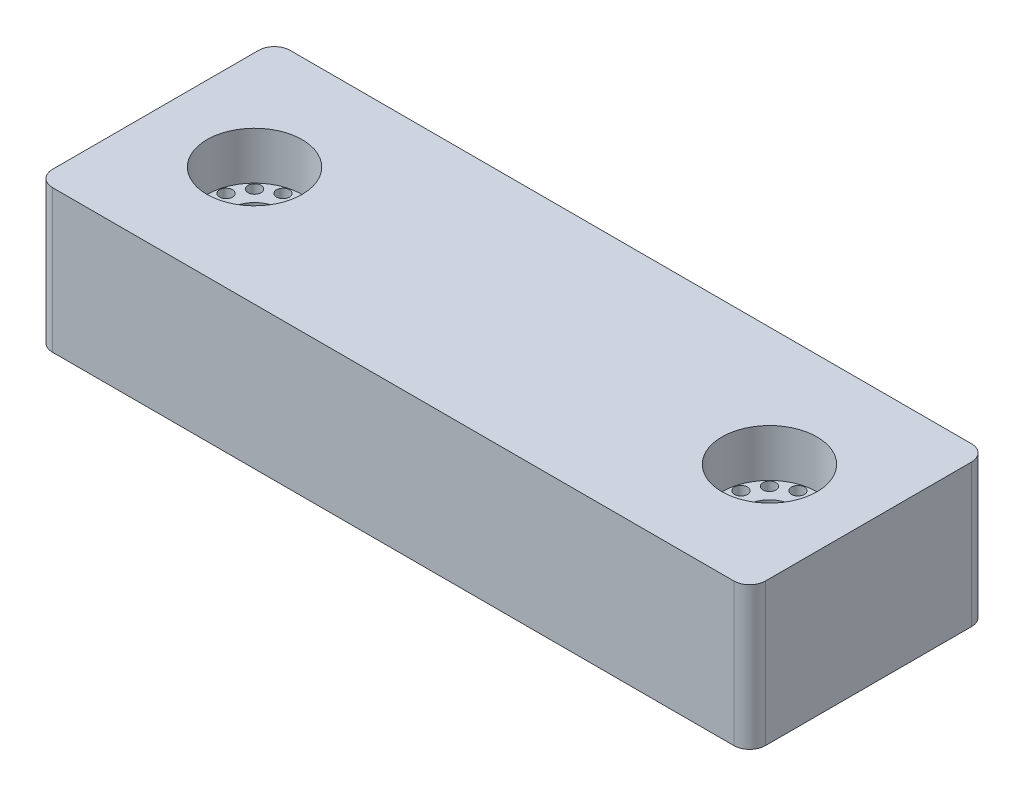
from build123d import *

# Parameters (mm, degrees)
SKETCH1_R           = 3
SKETCH1_R_2         = 0.815869739
BOSS_EXTRUDE1_DEPTH = 18
SKETCH2_R           = 6
CUT_EXTRUDE1_DEPTH  = 6


with BuildPart() as part:
    # Sketch1 → Boss-Extrude1 (new body)
    with BuildSketch(Plane(origin=(0, 0, 0), x_dir=(1, 0, 0), z_dir=(0, 1, 0))):
        with BuildLine():
            Line((-45, 13), (-45, -13))
            ThreePointArc((-45, -13), (-44.414213562, -14.414213562), (-43, -15))
            Line((-43, -15), (43, -15))
            ThreePointArc((43, -15), (44.414213562, -14.414213562), (45, -13))
            Line((45, -13), (45, 13))
            ThreePointArc((45, 13), (44.414213562, 14.414213562), (43, 15))
            Line((43, 15), (-43, 15))
            ThreePointArc((-43, 15), (-44.414213562, 14.414213562), (-45, 13))
        make_face()
        with Locations((-32.5, 0)):
            Circle(SKETCH1_R, mode=Mode.SUBTRACT)
        with Locations((32.5, 0)):
            Circle(SKETCH1_R, mode=Mode.SUBTRACT)
        with Locations((-31.184130261, 4.910892723)):
            Circle(SKETCH1_R_2, mode=Mode.SUBTRACT)
        with Locations((-33.815869739, 4.910892723)):
            Circle(SKETCH1_R_2, mode=Mode.SUBTRACT)
        with Locations((-36.095022984, 3.595022984)):
            Circle(SKETCH1_R_2, mode=Mode.SUBTRACT)
        with Locations((-37.410892723, 1.315869739)):
            Circle(SKETCH1_R_2, mode=Mode.SUBTRACT)
        with Locations((-37.410892723, -1.315869739)):
            Circle(SKETCH1_R_2, mode=Mode.SUBTRACT)
        with Locations((-36.095022984, -3.595022984)):
            Circle(SKETCH1_R_2, mode=Mode.SUBTRACT)
        with Locations((-33.815869739, -4.910892723)):
            Circle(SKETCH1_R_2, mode=Mode.SUBTRACT)
        with Locations((-31.184130261, -4.910892723)):
            Circle(SKETCH1_R_2, mode=Mode.SUBTRACT)
        with Locations((-28.904977016, -3.595022984)):
            Circle(SKETCH1_R_2, mode=Mode.SUBTRACT)
        with Locations((-27.589107277, -1.315869739)):
            Circle(SKETCH1_R_2, mode=Mode.SUBTRACT)
        with Locations((-27.589107277, 1.315869739)):
            Circle(SKETCH1_R_2, mode=Mode.SUBTRACT)
        with Locations((-28.904977016, 3.595022984)):
            Circle(SKETCH1_R_2, mode=Mode.SUBTRACT)
        with Locations((31.184130261, 4.910892723)):
            Circle(SKETCH1_R_2, mode=Mode.SUBTRACT)
        with Locations((33.815869739, 4.910892723)):
            Circle(SKETCH1_R_2, mode=Mode.SUBTRACT)
        with Locations((36.095022984, 3.595022984)):
            Circle(SKETCH1_R_2, mode=Mode.SUBTRACT)
        with Locations((37.410892723, 1.315869739)):
            Circle(SKETCH1_R_2, mode=Mode.SUBTRACT)
        with Locations((37.410892723, -1.315869739)):
            Circle(SKETCH1_R_2, mode=Mode.SUBTRACT)
        with Locations((36.095022984, -3.595022984)):
            Circle(SKETCH1_R_2, mode=Mode.SUBTRACT)
        with Locations((33.815869739, -4.910892723)):
            Circle(SKETCH1_R_2, mode=Mode.SUBTRACT)
        with Locations((31.184130261, -4.910892723)):
            Circle(SKETCH1_R_2, mode=Mode.SUBTRACT)
        with Locations((28.904977016, -3.595022984)):
            Circle(SKETCH1_R_2, mode=Mode.SUBTRACT)
        with Locations((27.589107277, -1.315869739)):
            Circle(SKETCH1_R_2, mode=Mode.SUBTRACT)
        with Locations((27.589107277, 1.315869739)):
            Circle(SKETCH1_R_2, mode=Mode.SUBTRACT)
        with Locations((28.904977016, 3.595022984)):
            Circle(SKETCH1_R_2, mode=Mode.SUBTRACT)
    extrude(amount=BOSS_EXTRUDE1_DEPTH)

    # Sketch2 → Cut-Extrude1 (cut)
    with BuildSketch(Plane(origin=(0, 18, 0), x_dir=(1, 0, 0), z_dir=(0, 1, 0))):
        with Locations((32.5, 0)):
            Circle(SKETCH2_R)
        with Locations((-32.5, 0)):
            Circle(SKETCH2_R)
    extrude(amount=-CUT_EXTRUDE1_DEPTH, mode=Mode.SUBTRACT)


solid = part.part
